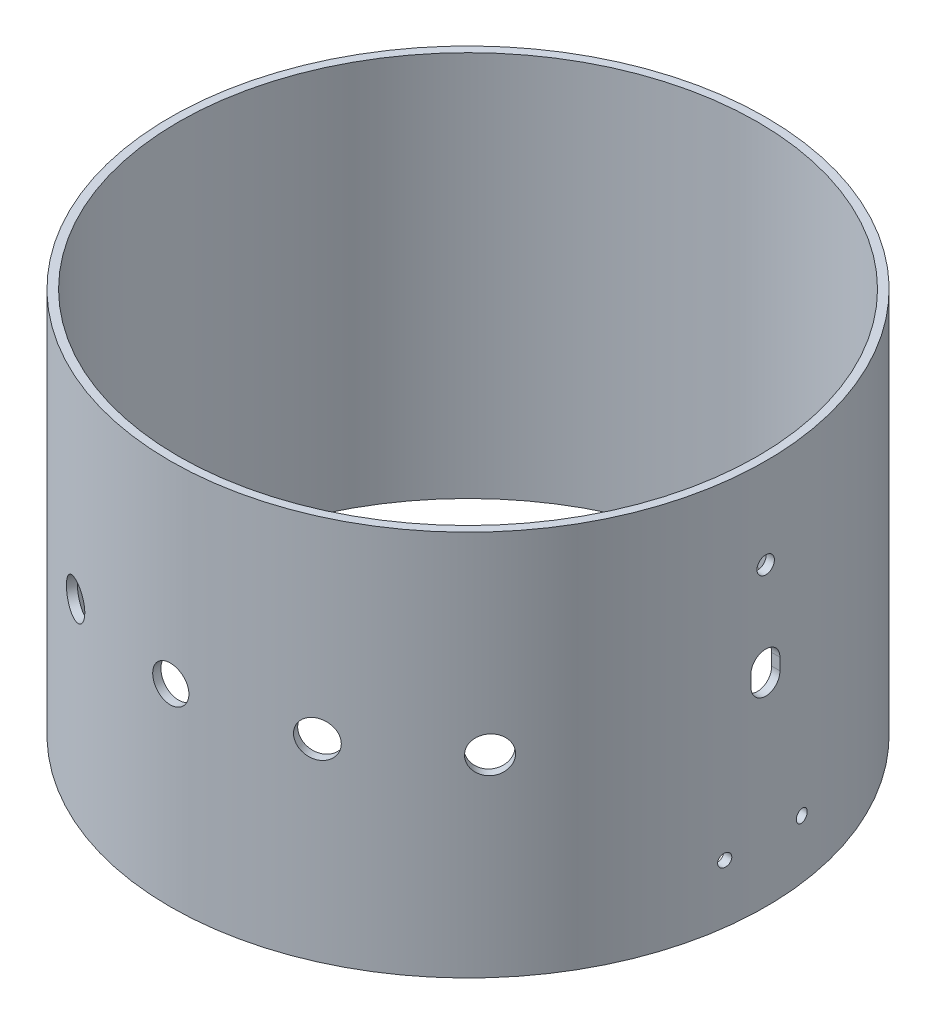
from build123d import *

# Parameters (mm, degrees)
BODY_TUBE_PROFILE_R               = 78.359
BODY_TUBE_PROFILE_R_2             = 76.2
BODY_TUBE_EXTRUSTION_DEPTH        = 101.6
F_3_8_0_375_DIAMETER_HOLE1_REACH  = 204.542
F_3_8_0_375_DIAMETER_HOLE1_BORE_R = 4.7625
CIRPATTERN1_COUNT                 = 3
CIRPATTERN1_ANGLE                 = 48
CIRPATTERN1_THE_OTHER_WAY_COUNT   = 3
CIRPATTERN1_THE_OTHER_WAY_ANGLE   = 48
CUT_EXTRUDE1_REACH                = 204.542
CUT_EXTRUDE1_END_RADIUS           = 76.2
SKETCH4_R                         = 1.651
SKETCH4_R_2                       = 2.286
CUT_EXTRUDE2_REACH                = 204.542


with BuildPart() as part:
    # Body Tube Profile → Body Tube Extrustion (new body)
    with BuildSketch(Plane(origin=(0, 0, 0), x_dir=(1, 0, 0), z_dir=(0, 1, 0))):
        with Locations(Location((0, 0, 0), (0, 0, 270))):
            Circle(BODY_TUBE_PROFILE_R)
        with Locations(Location((0, 0, 0), (0, 0, 270))):
            Circle(BODY_TUBE_PROFILE_R_2, mode=Mode.SUBTRACT)
    extrude(amount=BODY_TUBE_EXTRUSTION_DEPTH)

    # 3/8 (0.375) Diameter Hole1 bore → 3/8 (0.375) Diameter Hole1 (cut, up to next)
    with BuildSketch(Plane.XY.offset(78.359), mode=Mode.PRIVATE) as f_3_8_0_375_diameter_hole1_sk1:
        with Locations((0, 50.8)):
            Circle(F_3_8_0_375_DIAMETER_HOLE1_BORE_R)
    f_3_8_0_375_diameter_hole1_tool1 = extrude(f_3_8_0_375_diameter_hole1_sk1.sketch, amount=-F_3_8_0_375_DIAMETER_HOLE1_REACH, mode=Mode.PRIVATE) & part.part
    f_3_8_0_375_diameter_hole1 = f_3_8_0_375_diameter_hole1_tool1.solids().sort_by_distance((0, 50.8, 78.359))[0]
    add(f_3_8_0_375_diameter_hole1, mode=Mode.SUBTRACT)

    # CirPattern1: 3/8 (0.375) Diameter Hole1 ×3 about axis
    cirpattern1_axis = Axis((0, 101.6, 0), (0, 1, 0))
    for i in range(1, CIRPATTERN1_COUNT):
        add(f_3_8_0_375_diameter_hole1.rotate(cirpattern1_axis, i * CIRPATTERN1_ANGLE / (CIRPATTERN1_COUNT - 1)), mode=Mode.SUBTRACT)

    # CirPattern1 the other way: 3/8 (0.375) Diameter Hole1 ×3 about axis
    cirpattern1_the_other_way_axis = Axis((0, 101.6, 0), (0, -1, 0))
    for i in range(1, CIRPATTERN1_THE_OTHER_WAY_COUNT):
        add(f_3_8_0_375_diameter_hole1.rotate(cirpattern1_the_other_way_axis, i * CIRPATTERN1_THE_OTHER_WAY_ANGLE / (CIRPATTERN1_THE_OTHER_WAY_COUNT - 1)), mode=Mode.SUBTRACT)

    # Cut-Extrude1: up to this cylinder (the profile starts outside it)
    cut_extrude1_end = Plane(origin=(0, 46.658948, 0), z_dir=(0, -1, 0)) * Cylinder(CUT_EXTRUDE1_END_RADIUS, 625.065886, mode=Mode.PRIVATE)
    # Sketch4 → Cut-Extrude1 (cut, up to the surface)
    with BuildSketch(Plane(origin=(78.359, 0, 0), x_dir=(0, 0, -1), z_dir=(1, 0, 0)), mode=Mode.PRIVATE) as cut_extrude1_sk1:
        with Locations((10.139493437, 15.368005332)):
            Circle(SKETCH4_R)
    cut_extrude1_tool1 = extrude(cut_extrude1_sk1.sketch, amount=-CUT_EXTRUDE1_REACH, mode=Mode.PRIVATE) - cut_extrude1_end
    add(cut_extrude1_tool1.solids().sort_by_distance((78.359, 15.368005, -10.139493))[0], mode=Mode.SUBTRACT)
    # Sketch4 → Cut-Extrude1 (cut, up to the surface)
    with BuildSketch(Plane(origin=(78.359, 0, 0), x_dir=(0, 0, -1), z_dir=(1, 0, 0)), mode=Mode.PRIVATE) as cut_extrude1_sk2:
        with Locations((-10.139493437, 15.368005332)):
            Circle(SKETCH4_R)
    cut_extrude1_tool2 = extrude(cut_extrude1_sk2.sketch, amount=-CUT_EXTRUDE1_REACH, mode=Mode.PRIVATE) - cut_extrude1_end
    add(cut_extrude1_tool2.solids().sort_by_distance((78.359, 15.368005, 10.139493))[0], mode=Mode.SUBTRACT)
    # Sketch4 → Cut-Extrude1 (cut, up to the surface)
    with BuildSketch(Plane(origin=(78.359, 0, 0), x_dir=(0, 0, -1), z_dir=(1, 0, 0)), mode=Mode.PRIVATE) as cut_extrude1_sk3:
        with Locations((0, 77.94989109)):
            Circle(SKETCH4_R_2)
    cut_extrude1_tool3 = extrude(cut_extrude1_sk3.sketch, amount=-CUT_EXTRUDE1_REACH, mode=Mode.PRIVATE) - cut_extrude1_end
    add(cut_extrude1_tool3.solids().sort_by_distance((78.359, 77.949891, 0))[0], mode=Mode.SUBTRACT)

    # Sketch5 → Cut-Extrude2 (cut, up to next)
    with BuildSketch(Plane(origin=(78.359, 0, 0), x_dir=(0, 0, -1), z_dir=(1, 0, 0)), mode=Mode.PRIVATE) as cut_extrude2_sk1:
        with BuildLine():
            Line((-3.81, 54.937587864), (-3.81, 51.834014442))
            ThreePointArc((-3.81, 51.834014442), (0, 48.024014442), (3.81, 51.834014442))
            Line((3.81, 51.834014442), (3.81, 54.937587864))
            ThreePointArc((3.81, 54.937587864), (0, 58.747587864), (-3.81, 54.937587864))
        make_face()
    cut_extrude2_tool1 = extrude(cut_extrude2_sk1.sketch, amount=-CUT_EXTRUDE2_REACH, mode=Mode.PRIVATE) & part.part
    add(cut_extrude2_tool1.solids().sort_by_distance((78.359, 53.385801, 0))[0], mode=Mode.SUBTRACT)


solid = part.part
